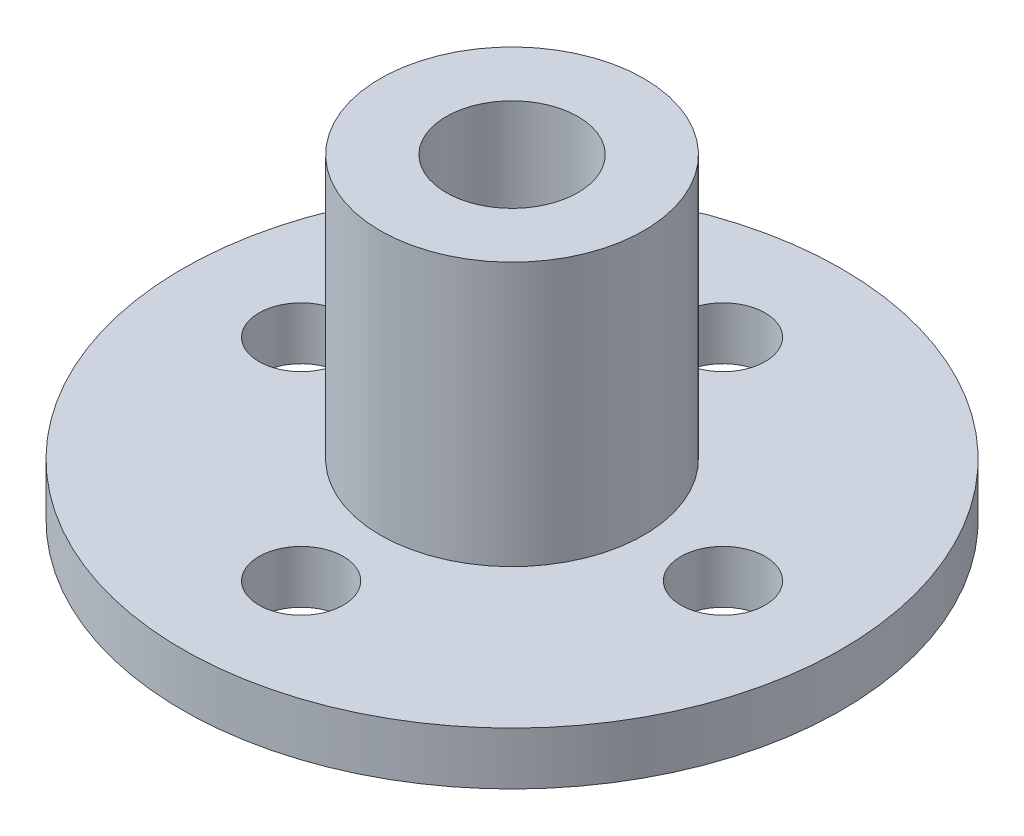
from build123d import *

# Parameters (mm, degrees)
SKETCH_2_R          = 1.6
CUT_EXTRUDE_1_DEPTH = 10


with BuildPart() as part:
    # 草图1 → 旋转1 (revolve)
    with BuildSketch(Plane.XY):
        Polygon((-2.5, 0.013967073), (-12.5, 0.013967073), (-12.5, 2.013967073), (-5, 2.013967073), (-5, 12.013967073), (-2.5, 12.013967073), align=None)
    revolve(axis=Axis((0, 0, 0), (0, 1, 0)))

    # 草图2 → 切除-拉伸1 (cut)
    with BuildSketch(Plane.XZ.offset(-0.013967073)):
        with Locations((-8, 0)):
            Circle(SKETCH_2_R)
        with Locations((0, 8)):
            Circle(SKETCH_2_R)
        with Locations((8, 0)):
            Circle(SKETCH_2_R)
        with Locations((0, -8)):
            Circle(SKETCH_2_R)
    extrude(amount=-CUT_EXTRUDE_1_DEPTH, mode=Mode.SUBTRACT)


solid = part.part
